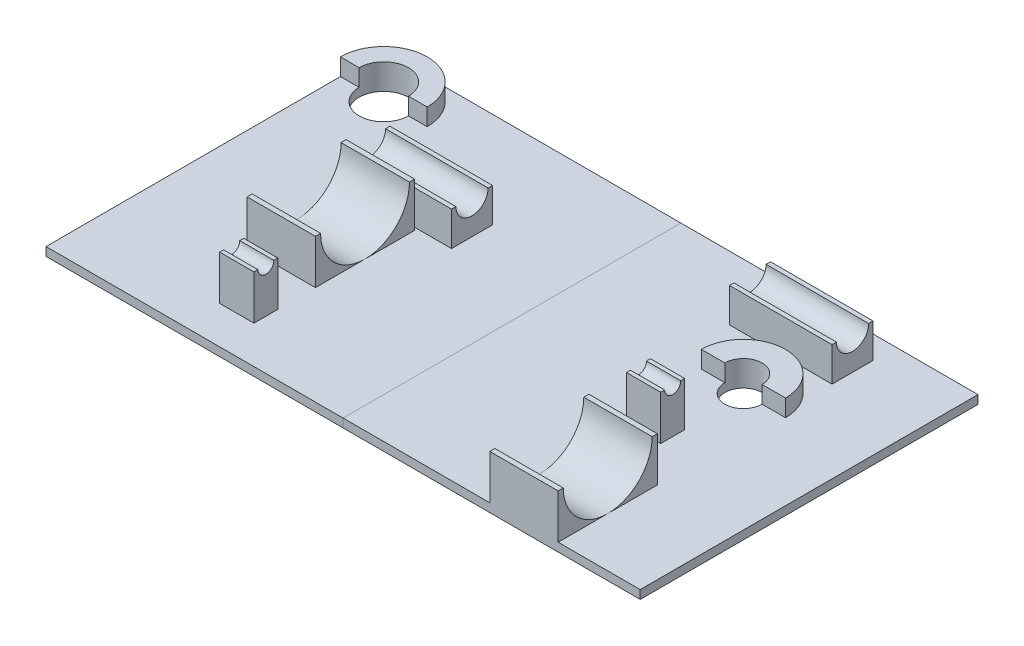
from build123d import *
from build123d.topology import SkipClean

# Parameters (mm, degrees)
SKETCH1_W                   = 220.7514
SKETCH1_H                   = 125.5014
SKETCH1_R                   = 9.159861243
SKETCH1_R_2                 = 6.914797213
BASE_DEPTH                  = 3.175
SKETCH1_3_W                 = 38.1
SKETCH1_3_H                 = 15.24
RATCHET_HANDLE_DEPTH        = 15.875
RATCHET_HEAD_DEPTH          = 9.525
SKETCH1_5_W                 = 25.4
SKETCH1_5_H                 = 36.83
SKETCH1_5_W_2               = 12.7
SKETCH1_5_H_2               = 8.89
SCREWDRIVER_DEPTH           = 19.685
SKETCH2_R                   = 2.9845
SKETCH2_R_2                 = 16.51
SCREWDRIVER_LEFT_CUT_DEPTH  = 169.288133204
SKETCH2_3_R                 = 16.51
SKETCH2_3_R_2               = 2.9845
SCREWDRIVER_RIGHT_CUT_DEPTH = 169.288133204
SKETCH2_4_R                 = 5.9817
FRONT_RATCHET_CUT_DEPTH     = 169.288133204
SKETCH2_5_R                 = 5.9817
BACK_RATCHET_CUT_DEPTH      = 169.288133204
SPLIT2_SURFACE_1_BACK       = 255.694
SPLIT2_SURFACE_1_DEPTH      = 511.388
SPLIT2_SURFACE_2_BACK       = 255.694
SPLIT2_SURFACE_2_DEPTH      = 511.388


with BuildPart() as part:
    # Sketch1 → Base (new body)
    with BuildSketch(Plane(origin=(0, 0, 0), x_dir=(1, 0, 0), z_dir=(0, 1, 0))):
        with Locations((0, 62.7507)):
            Rectangle(SKETCH1_W, SKETCH1_H)
        with Locations((-94.2467, 109.3724)):
            Circle(SKETCH1_R, mode=Mode.SUBTRACT)
        with Locations((66.4464, 82.296)):
            Circle(SKETCH1_R_2, mode=Mode.SUBTRACT)
    extrude(amount=BASE_DEPTH)

    # Sketch1_3 → Ratchet Handle (add)
    with BuildSketch(Plane(origin=(0, 0, 0), x_dir=(1, 0, 0), z_dir=(0, 1, 0))):
        with Locations((-53.4543, 82.296)):
            Rectangle(SKETCH1_3_W, SKETCH1_3_H)
        with Locations((60.8457, 109.3724)):
            Rectangle(SKETCH1_3_W, SKETCH1_3_H)
    extrude(amount=RATCHET_HANDLE_DEPTH)

    # Sketch1_4 → Ratchet Head (add)
    with SkipClean():  # the faces are left unmerged after this step: merging them gives an invalid solid
        with BuildSketch(Plane(origin=(0, 0, 0), x_dir=(1, 0, 0), z_dir=(0, 1, 0))):
            with BuildLine():
                ThreePointArc((-78.1177, 109.3724), (-94.2467, 125.5014), (-110.3757, 109.3724))
                Line((-110.3757, 109.3724), (-103.406561243, 109.3724))
                ThreePointArc((-103.406561243, 109.3724), (-94.2467, 118.532261243), (-85.086838757, 109.3724))
                Line((-85.086838757, 109.3724), (-78.1177, 109.3724))
            make_face()
            with BuildLine():
                ThreePointArc((59.531602787, 82.296), (66.4464, 89.210797213), (73.361197213, 82.296))
                Line((73.361197213, 82.296), (82.0928, 82.296))
                ThreePointArc((82.0928, 82.296), (66.4464, 97.9424), (50.8, 82.296))
                Line((50.8, 82.296), (59.531602787, 82.296))
            make_face()
        extrude(amount=RATCHET_HEAD_DEPTH)

    # Sketch1_5 → Screwdriver (add)
    with SkipClean():  # the faces are left unmerged after this step: merging them gives an invalid solid
        with BuildSketch(Plane(origin=(0, 0, 0), x_dir=(1, 0, 0), z_dir=(0, 1, 0))):
            with Locations((67.1957, 18.415)):
                Rectangle(SKETCH1_5_W, SKETCH1_5_H)
            with Locations((-53.4543, 18.415)):
                Rectangle(SKETCH1_5_W_2, SKETCH1_5_H_2)
            with Locations((60.8457, 55.245)):
                Rectangle(SKETCH1_5_W_2, SKETCH1_5_H_2)
            with Locations((-59.8043, 55.245)):
                Rectangle(SKETCH1_5_W, SKETCH1_5_H)
        extrude(amount=SCREWDRIVER_DEPTH)
    add(part.part.scale(1), mode=Mode.REPLACE)  # the faces are merged on a copy

    # Sketch2 → Screwdriver Left Cut (cut, through all)
    with BuildSketch(Plane(origin=(0, 0, 0), x_dir=(0, 0, -1), z_dir=(1, 0, 0))):
        with Locations((18.415, 19.685)):
            Circle(SKETCH2_R)
        with Locations((55.245, 19.685)):
            Circle(SKETCH2_R_2)
    extrude(amount=-SCREWDRIVER_LEFT_CUT_DEPTH, mode=Mode.SUBTRACT)

    # Sketch2_3 → Screwdriver Right Cut (cut, through all)
    with BuildSketch(Plane(origin=(0, 0, 0), x_dir=(0, 0, -1), z_dir=(1, 0, 0))):
        with Locations((18.415, 19.685)):
            Circle(SKETCH2_3_R)
        with Locations((55.245, 19.685)):
            Circle(SKETCH2_3_R_2)
    extrude(amount=SCREWDRIVER_RIGHT_CUT_DEPTH, mode=Mode.SUBTRACT)

    # Sketch2_4 → Front Ratchet Cut (cut, through all)
    with BuildSketch(Plane(origin=(0, 0, 0), x_dir=(0, 0, -1), z_dir=(1, 0, 0))):
        with Locations((82.296, 15.875)):
            Circle(SKETCH2_4_R)
    extrude(amount=-FRONT_RATCHET_CUT_DEPTH, mode=Mode.SUBTRACT)

    # Sketch2_5 → Back Ratchet Cut (cut, through all)
    with BuildSketch(Plane(origin=(0, 0, 0), x_dir=(0, 0, -1), z_dir=(1, 0, 0))):
        with Locations((109.3724, 15.875)):
            Circle(SKETCH2_5_R)
    extrude(amount=BACK_RATCHET_CUT_DEPTH, mode=Mode.SUBTRACT)


with BuildPart() as body_2:
    # Split2: the piece behind the surface
    add(part.part)
    # Split2 surface: a surface, the sketch's curves swept straight by 511.388 mm
    with BuildLine(Plane.XY.offset(-SPLIT2_SURFACE_1_BACK), mode=Mode.PRIVATE) as split2_surface_1_path:
        Line((0, 0), (0, 3.175))
    split2_surface_1 = Shell.extrude(split2_surface_1_path.wire(), (0 * SPLIT2_SURFACE_1_DEPTH, 0 * SPLIT2_SURFACE_1_DEPTH, 1 * SPLIT2_SURFACE_1_DEPTH))
    split(bisect_by=split2_surface_1, keep=Keep.BOTTOM)


with BuildPart() as part_1:
    add(part.part)

    # Split2: split by a surface, the side it looks to stays
    # Split2 surface: a surface, the sketch's curves swept straight by 511.388 mm
    with BuildLine(Plane.XY.offset(-SPLIT2_SURFACE_2_BACK), mode=Mode.PRIVATE) as split2_surface_2_path:
        Line((0, 0), (0, 3.175))
    split2_surface_2 = Shell.extrude(split2_surface_2_path.wire(), (0 * SPLIT2_SURFACE_2_DEPTH, 0 * SPLIT2_SURFACE_2_DEPTH, 1 * SPLIT2_SURFACE_2_DEPTH))
    split(bisect_by=split2_surface_2, keep=Keep.TOP)


solid = Compound([body_2.part, part_1.part])
